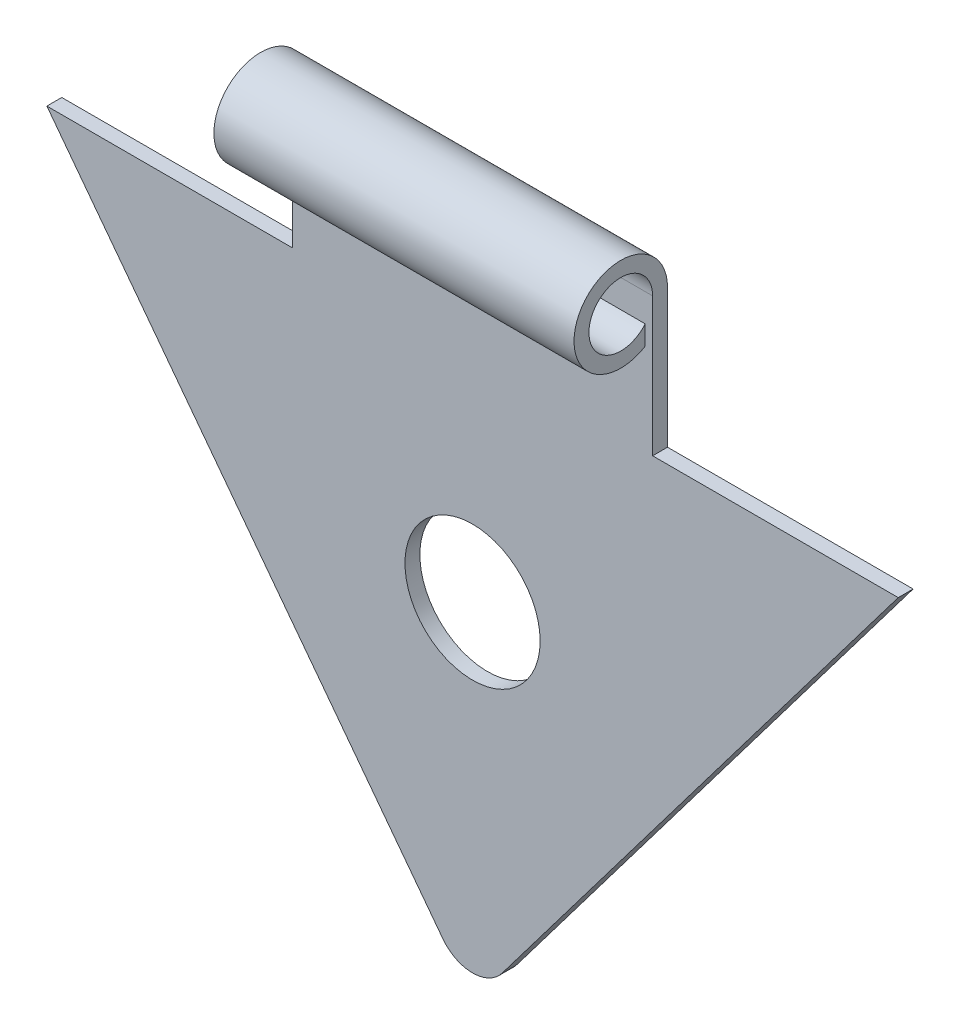
from build123d import *

# Parameters (mm, degrees)
SKETCH1_R                = 1.815
BOSS_EXTRUDE1_DEPTH      = 0.4
BOSS_EXTRUDE2_DEPTH      = 4.835
BOSS_EXTRUDE2_DEPTH_BACK = 4.835


with BuildPart() as part:
    # Sketch1 → Boss-Extrude1 (new body)
    with BuildSketch(Plane.XY):
        with BuildLine():
            Line((-11.43, 0), (11.43, 0))
            Line((11.43, 0), (0.797330841, -14.046658294))
            ThreePointArc((0.797330841, -14.046658294), (0, -14.44311581), (-0.797330841, -14.046658294))
            Line((-0.797330841, -14.046658294), (-11.43, 0))
        make_face()
        with Locations((0, -5.82)):
            Circle(SKETCH1_R, mode=Mode.SUBTRACT)
    extrude(amount=BOSS_EXTRUDE1_DEPTH)

    # Sketch3 → Boss-Extrude2 (add, two sides: drawn at the far end of the back side and taken through both)
    with BuildSketch(Plane(origin=(0, 0, 0), x_dir=(0, 0, -1), z_dir=(1, 0, 0)).offset(-BOSS_EXTRUDE2_DEPTH_BACK)):
        with BuildLine():
            Line((-0.4, 0), (0, 0))
            Line((0, 0), (0, 3.718694726))
            ThreePointArc((0, 3.718694726), (-2.349771666, 4.332290684), (-0.6, 2.648180831))
            Line((-0.6, 2.648180831), (-0.6, 3.16914946))
            ThreePointArc((-0.6, 3.16914946), (-2.058445704, 4.011098557), (-0.4, 3.718694726))
            Line((-0.4, 3.718694726), (-0.4, 0))
        make_face()
    extrude(amount=BOSS_EXTRUDE2_DEPTH + BOSS_EXTRUDE2_DEPTH_BACK)


solid = part.part
